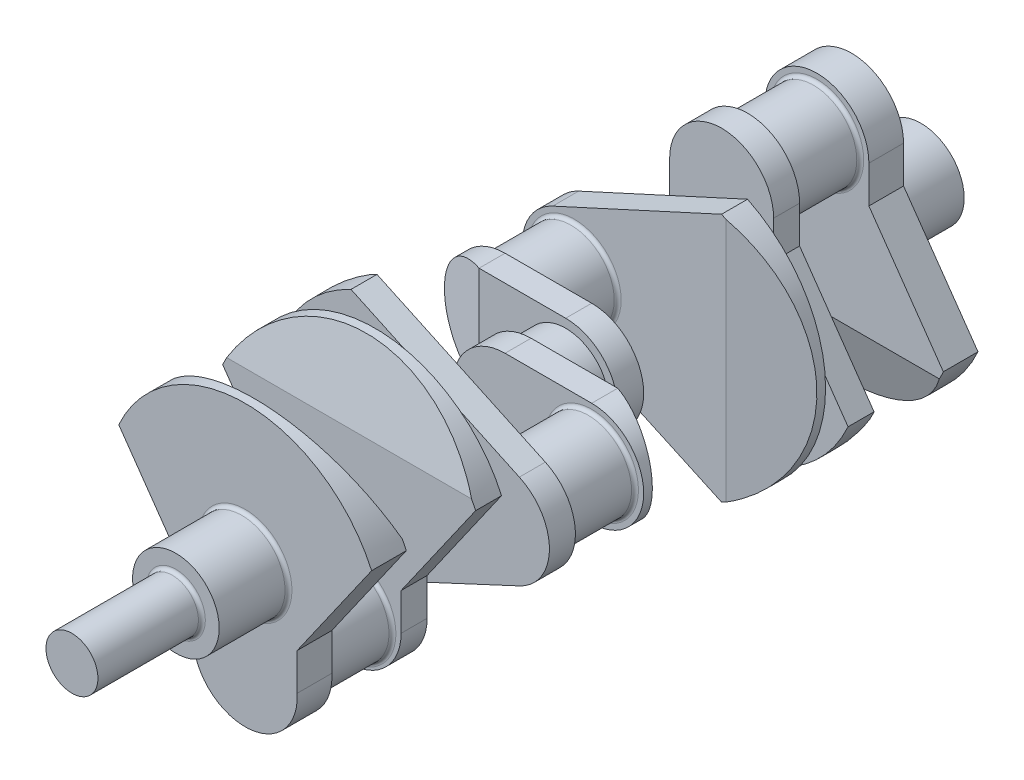
from build123d import *

# Parameters (mm, degrees)
SKETCH1_R            = 31.75
BOSS_EXTRUDE1_DEPTH  = 50.8
BOSS_EXTRUDE2_DEPTH  = 25.4
SKETCH3_R            = 31.75
BOSS_EXTRUDE3_DEPTH  = 50.8
BOSS_EXTRUDE4_DEPTH  = 19.05
SKETCH5_R            = 31.75
BOSS_EXTRUDE5_DEPTH  = 25.4
BOSS_EXTRUDE6_DEPTH  = 19.05
SKETCH7_R            = 31.75
BOSS_EXTRUDE7_DEPTH  = 50.8
BOSS_EXTRUDE8_DEPTH  = 19.05
SKETCH9_R            = 31.75
BOSS_EXTRUDE9_DEPTH  = 25.4
BOSS_EXTRUDE10_DEPTH = 19.05
SKETCH11_R           = 31.75
BOSS_EXTRUDE11_DEPTH = 50.8
BOSS_EXTRUDE12_DEPTH = 19.05
SKETCH13_R           = 31.75
BOSS_EXTRUDE13_DEPTH = 25.4
BOSS_EXTRUDE14_DEPTH = 19.05
SKETCH16_R           = 31.75
BOSS_EXTRUDE15_DEPTH = 50.8
BOSS_EXTRUDE16_DEPTH = 25.4
SKETCH18_R           = 31.75
BOSS_EXTRUDE17_DEPTH = 50.8
SKETCH19_R           = 19.05
BOSS_EXTRUDE18_DEPTH = 76.2
FILLET1_R            = 2.54
CUT_EXTRUDE1_DEPTH   = 138.557
CUT_EXTRUDE2_DEPTH   = 142.24


with BuildPart() as part:
    # Sketch1 → Boss-Extrude1 (new body)
    with BuildSketch(Plane.XY):
        Circle(SKETCH1_R)
    extrude(amount=BOSS_EXTRUDE1_DEPTH)

    # Sketch2 → Boss-Extrude2 (add)
    with BuildSketch(Plane.XY.offset(50.8)):
        with BuildLine():
            Line((-38.1, 63.5), (-38.1, 36.322))
            Line((-38.1, 36.322), (-92.680746838, -41.627384803))
            ThreePointArc((-92.680746838, -41.627384803), (0, -101.6), (92.680746838, -41.627384803))
            Line((92.680746838, -41.627384803), (38.1, 36.322))
            Line((38.1, 36.322), (38.1, 63.5))
            ThreePointArc((38.1, 63.5), (0, 101.6), (-38.1, 63.5))
        make_face()
    extrude(amount=BOSS_EXTRUDE2_DEPTH)

    # Sketch3 → Boss-Extrude3 (add)
    with BuildSketch(Plane.XY.offset(76.2)):
        with Locations((0, 63.5)):
            Circle(SKETCH3_R)
    extrude(amount=BOSS_EXTRUDE3_DEPTH)

    # Sketch4 → Boss-Extrude4 (add)
    with BuildSketch(Plane.XY.offset(127)):
        with BuildLine():
            Line((-38.1, 63.5), (-38.1, 36.322))
            Line((-38.1, 36.322), (-92.680746838, -41.627384803))
            ThreePointArc((-92.680746838, -41.627384803), (0, -101.6), (92.680746838, -41.627384803))
            Line((92.680746838, -41.627384803), (38.1, 36.322))
            Line((38.1, 36.322), (38.1, 63.5))
            ThreePointArc((38.1, 63.5), (0, 101.6), (-38.1, 63.5))
        make_face()
    extrude(amount=BOSS_EXTRUDE4_DEPTH)

    # Sketch5 → Boss-Extrude5 (add)
    with BuildSketch(Plane.XY.offset(146.05)):
        Circle(SKETCH5_R)
    extrude(amount=BOSS_EXTRUDE5_DEPTH)

    # Sketch6 → Boss-Extrude6 (add)
    with BuildSketch(Plane.XY.offset(171.45)):
        with BuildLine():
            Line((-79.369737814, 34.676103768), (44.401835082, 91.384008674))
            ThreePointArc((44.401835082, 91.384008674), (101.599998729, 0.016072292), (44.43074527, -91.369956084))
            Line((44.43074527, -91.369956084), (-79.321957026, -34.620881991))
            ThreePointArc((-79.321957026, -34.620881991), (-101.59997925, 0.012266499), (-79.369737814, 34.676103768))
        make_face()
    extrude(amount=BOSS_EXTRUDE6_DEPTH)

    # Sketch7 → Boss-Extrude7 (add)
    with BuildSketch(Plane.XY.offset(190.5)):
        with Locations((-63.499988306, 0.038536726)):
            Circle(SKETCH7_R)
    extrude(amount=BOSS_EXTRUDE7_DEPTH)

    # Sketch8 → Boss-Extrude8 (add)
    with BuildSketch(Plane.XY.offset(241.3)):
        with BuildLine():
            Line((-63.5, 38.1), (0, 38.1))
            ThreePointArc((0, 38.1), (38.1, 0), (0, -38.1))
            Line((0, -38.1), (-63.5, -38.1))
            ThreePointArc((-63.5, -38.1), (-101.6, 0), (-63.5, 38.1))
        make_face()
    extrude(amount=BOSS_EXTRUDE8_DEPTH)

    # Sketch9 → Boss-Extrude9 (add)
    with BuildSketch(Plane.XY.offset(260.35)):
        Circle(SKETCH9_R)
    extrude(amount=BOSS_EXTRUDE9_DEPTH)

    # Sketch10 → Boss-Extrude10 (add)
    with BuildSketch(Plane.XY.offset(285.75)):
        with BuildLine():
            Line((0, 38.1), (63.5, 38.1))
            ThreePointArc((63.5, 38.1), (101.6, 0), (63.5, -38.1))
            Line((63.5, -38.1), (0, -38.1))
            ThreePointArc((0, -38.1), (-38.1, 0), (0, 38.1))
        make_face()
    extrude(amount=BOSS_EXTRUDE10_DEPTH)

    # Sketch11 → Boss-Extrude11 (add)
    with BuildSketch(Plane.XY.offset(304.8)):
        with Locations((63.5, 0)):
            Circle(SKETCH11_R)
    extrude(amount=BOSS_EXTRUDE11_DEPTH)

    # Sketch12 → Boss-Extrude12 (add)
    with BuildSketch(Plane.XY.offset(355.6)):
        with BuildLine():
            Line((-43.092133514, 92.00884756), (80.327538284, 34.539087257))
            ThreePointArc((80.327538284, 34.539087257), (102.344582976, 0), (80.327538284, -34.539087257))
            Line((80.327538284, -34.539087257), (-43.092133514, -92.00884756))
            ThreePointArc((-43.092133514, -92.00884756), (-101.6, 0), (-43.092133514, 92.00884756))
        make_face()
    extrude(amount=BOSS_EXTRUDE12_DEPTH)

    # Sketch13 → Boss-Extrude13 (add)
    with BuildSketch(Plane.XY.offset(374.65)):
        Circle(SKETCH13_R)
    extrude(amount=BOSS_EXTRUDE13_DEPTH)

    # Sketch15 → Boss-Extrude14 (add)
    with BuildSketch(Plane.XY.offset(400.05)):
        with BuildLine():
            Line((-38.1, -63.5), (-38.1, -36.322))
            Line((-38.1, -36.322), (-92.680746838, 41.627384803))
            ThreePointArc((-92.680746838, 41.627384803), (0, 101.6), (92.680746838, 41.627384803))
            Line((92.680746838, 41.627384803), (38.1, -36.322))
            Line((38.1, -36.322), (38.1, -63.5))
            ThreePointArc((38.1, -63.5), (0, -101.6), (-38.1, -63.5))
        make_face()
    extrude(amount=BOSS_EXTRUDE14_DEPTH)

    # Sketch16 → Boss-Extrude15 (add)
    with BuildSketch(Plane.XY.offset(419.1)):
        with Locations((0, -65.694590163)):
            Circle(SKETCH16_R)
    extrude(amount=BOSS_EXTRUDE15_DEPTH)

    # Sketch17 → Boss-Extrude16 (add)
    with BuildSketch(Plane.XY.offset(469.9)):
        with BuildLine():
            Line((-92.680746838, 41.627384803), (-38.1, -36.322))
            Line((-38.1, -36.322), (-38.1, -63.5))
            ThreePointArc((-38.1, -63.5), (0, -103.857742889), (38.1, -63.5))
            Line((38.1, -63.5), (38.1, -36.322))
            Line((38.1, -36.322), (92.680746838, 41.627384803))
            ThreePointArc((92.680746838, 41.627384803), (0, 101.6), (-92.680746838, 41.627384803))
        make_face()
    extrude(amount=BOSS_EXTRUDE16_DEPTH)

    # Sketch18 → Boss-Extrude17 (add)
    with BuildSketch(Plane.XY.offset(495.3)):
        Circle(SKETCH18_R)
    extrude(amount=BOSS_EXTRUDE17_DEPTH)

    # Sketch19 → Boss-Extrude18 (add)
    with BuildSketch(Plane.XY.offset(546.1)):
        Circle(SKETCH19_R)
    extrude(amount=BOSS_EXTRUDE18_DEPTH)

    # Fillet1
    fillet1_edges = [part.edges().sort_by_distance(p)[0] for p in [
        (-31.75, 0, 374.65),
        (-31.75, 0, 400.05),
        (-31.75, -65.694590163, 419.1),
        (-31.75, -65.694590163, 469.9),
        (-31.75, 0, 495.3),
        (-19.05, 0, 546.1),
        (-31.75, 63.5, 76.2),
        (-31.75, 63.5, 127),
        (-31.75, 0, 50.8),
        (-31.75, 0, 146.05),
        (-31.75, 0, 171.45),
        (-95.249988306, 0.038536726, 190.5),
        (-95.249988306, 0.038536726, 241.3),
        (-31.75, 0, 285.75),
        (31.75, 0, 304.8),
        (31.75, 0, 355.6),
    ]]
    fillet(fillet1_edges, radius=FILLET1_R)

    # Sketch20 → Cut-Extrude1 (cut, symmetric)
    with BuildSketch(Plane(origin=(0, 0, 0), x_dir=(0, 0, -1), z_dir=(1, 0, 0))):
        Polygon((-488.95, 101.6), (-469.9, 47.625), (-469.9, 101.6), align=None)
        Polygon((-419.1, 47.625), (-419.1, 101.6), (-406.4, 101.6), align=None)
        Polygon((-139.7, -101.6), (-127, -101.6), (-127, -47.625), align=None)
        Polygon((-57.15, -101.6), (-76.2, -101.6), (-76.2, -47.625), align=None)
    extrude(amount=CUT_EXTRUDE1_DEPTH, both=True, mode=Mode.SUBTRACT)

    # Sketch21 → Cut-Extrude2 (cut, symmetric)
    with BuildSketch(Plane(origin=(0, 0, 0), x_dir=(1, 0, 0), z_dir=(0, 1, 0))):
        Polygon((101.6, -177.8), (101.6, -190.5), (47.625, -190.5), align=None)
        Polygon((-101.6, -247.65), (-101.6, -260.35), (-63.5, -260.35), align=None)
        Polygon((63.5, -285.75), (101.6, -285.75), (101.6, -298.45), align=None)
        Polygon((-101.6, -355.6), (-101.6, -368.3), (-47.625, -355.6), align=None)
    extrude(amount=CUT_EXTRUDE2_DEPTH, both=True, mode=Mode.SUBTRACT)


solid = part.part
